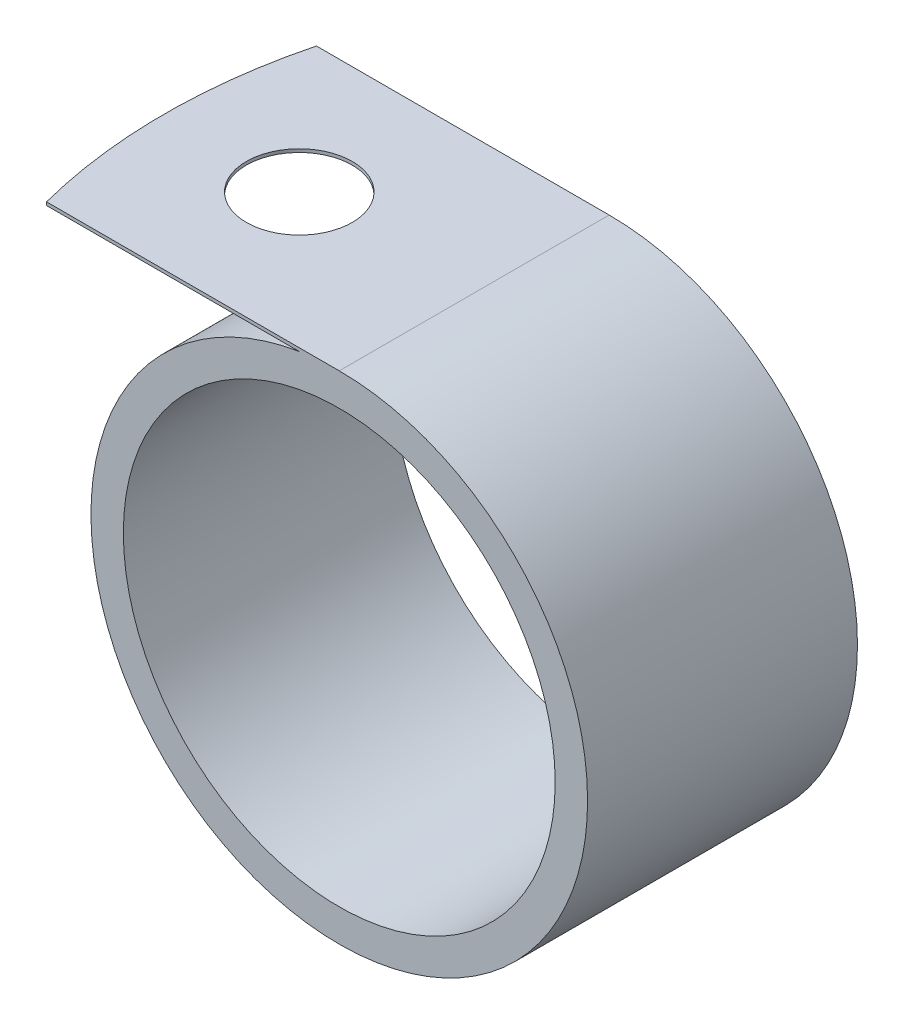
from build123d import *

# Parameters (mm, degrees)
SKETCH1_R           = 11.684
SKETCH1_R_2         = 10.16
BOSS_EXTRUDE1_DEPTH = 6.35
CUT_EXTRUDE1_REACH  = 25.368
SKETCH5_R           = 2.4892


with BuildPart() as part:
    # Sketch1 → Boss-Extrude1 (new body, symmetric)
    with BuildSketch(Plane.XY):
        Circle(SKETCH1_R)
        Circle(SKETCH1_R_2, mode=Mode.SUBTRACT)
        with BuildLine():
            ThreePointArc((-1.880972472, 11.5316), (-0.943568122, 11.645837677), (0, 11.684))
            Line((0, 11.684), (-14.580972472, 11.684))
            Line((-14.580972472, 11.684), (-14.580972472, 11.5316))
            Line((-14.580972472, 11.5316), (-1.880972472, 11.5316))
        make_face()
    extrude(amount=BOSS_EXTRUDE1_DEPTH, both=True)

    # Sketch5 → Cut-Extrude1 (cut, up to next)
    with BuildSketch(Plane(origin=(0, 11.684, 0), x_dir=(1, 0, 0), z_dir=(0, 1, 0)), mode=Mode.PRIVATE) as cut_extrude1_sk1:
        with BuildLine():
            ThreePointArc((-14.580972472, 0), (-14.378526757, 3.200509029), (-13.77441672, 6.35))
            Line((-13.77441672, 6.35), (-14.580972472, 6.35))
            Line((-14.580972472, 6.35), (-14.580972472, 0))
        make_face()
    cut_extrude1_tool1 = extrude(cut_extrude1_sk1.sketch, amount=-CUT_EXTRUDE1_REACH, mode=Mode.PRIVATE) & part.part
    add(cut_extrude1_tool1.solids().sort_by_distance((-14.339679, 11.684, -4.767585))[0], mode=Mode.SUBTRACT)
    # Sketch5 → Cut-Extrude1 (cut, up to next)
    with BuildSketch(Plane(origin=(0, 11.684, 0), x_dir=(1, 0, 0), z_dir=(0, 1, 0)), mode=Mode.PRIVATE) as cut_extrude1_sk2:
        with BuildLine():
            ThreePointArc((-13.77441672, -6.35), (-14.378526757, -3.200509029), (-14.580972472, 0))
            Line((-14.580972472, 0), (-14.580972472, -6.35))
            Line((-14.580972472, -6.35), (-13.77441672, -6.35))
        make_face()
    cut_extrude1_tool2 = extrude(cut_extrude1_sk2.sketch, amount=-CUT_EXTRUDE1_REACH, mode=Mode.PRIVATE) & part.part
    add(cut_extrude1_tool2.solids().sort_by_distance((-14.339679, 11.684, 4.767585))[0], mode=Mode.SUBTRACT)
    # Sketch5 → Cut-Extrude1 (cut, up to next)
    with BuildSketch(Plane(origin=(0, 11.684, 0), x_dir=(1, 0, 0), z_dir=(0, 1, 0)), mode=Mode.PRIVATE) as cut_extrude1_sk3:
        with Locations((-8.230972472, 0)):
            Circle(SKETCH5_R)
    cut_extrude1_tool3 = extrude(cut_extrude1_sk3.sketch, amount=-CUT_EXTRUDE1_REACH, mode=Mode.PRIVATE) & part.part
    add(cut_extrude1_tool3.solids().sort_by_distance((-8.230972, 11.684, 0))[0], mode=Mode.SUBTRACT)


solid = part.part
